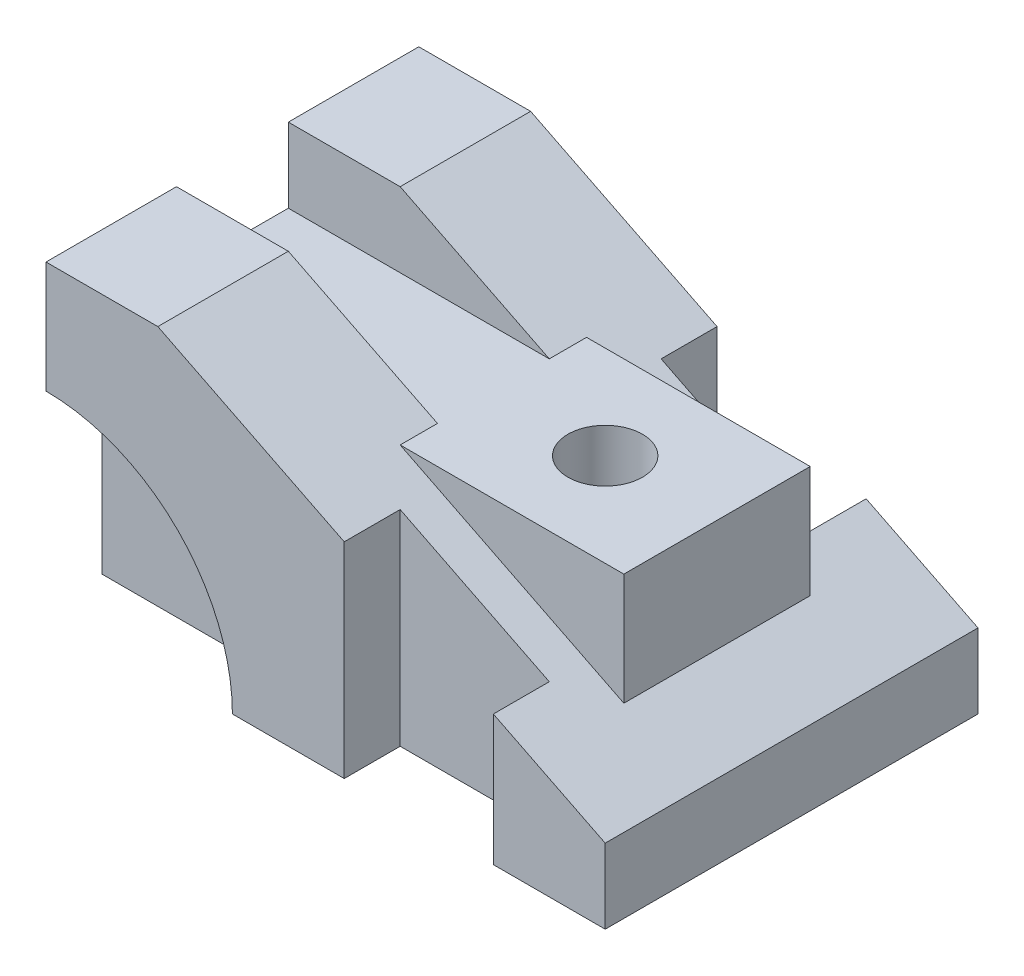
from build123d import *

# Parameters (mm, degrees)
BOSS_EXTRUDE1_DEPTH = 100
SKETCH2_R           = 50
CUT_EXTRUDE1_DEPTH  = 15
SKETCH3_R           = 50
CUT_EXTRUDE2_DEPTH  = 15
SKETCH4_W           = 40
SKETCH4_H           = 15
CUT_EXTRUDE3_DEPTH  = 75
SKETCH5_W           = 60
SKETCH5_H           = 50
BOSS_EXTRUDE2_DEPTH = 60
SKETCH7_W           = 30
SKETCH7_H           = 20
CUT_EXTRUDE4_DEPTH  = 100
SKETCH8_R           = 10
CUT_EXTRUDE5_DEPTH  = 100


with BuildPart() as part:
    # Sketch1 → Boss-Extrude1 (new body)
    with BuildSketch(Plane.XY):
        Polygon((-52.06185567, 38.608247423), (-52.06185567, -41.391752577), (97.93814433, -41.391752577), (97.93814433, -21.391752577), (-22.06185567, 38.608247423), align=None)
    extrude(amount=-BOSS_EXTRUDE1_DEPTH)

    # Sketch2 → Cut-Extrude1 (cut)
    with BuildSketch(Plane.XY):
        with Locations((-52.06185567, -41.391752577)):
            Circle(SKETCH2_R)
    extrude(amount=-CUT_EXTRUDE1_DEPTH, mode=Mode.SUBTRACT)

    # Sketch3 → Cut-Extrude2 (cut)
    with BuildSketch(Plane(origin=(0, 0, -100), x_dir=(-1, 0, 0), z_dir=(0, 0, -1))):
        with Locations((52.06185567, -41.391752577)):
            Circle(SKETCH3_R)
    extrude(amount=-CUT_EXTRUDE2_DEPTH, mode=Mode.SUBTRACT)

    # Sketch4 → Cut-Extrude3 (cut)
    with BuildSketch(Plane.XZ.offset(41.391752577)):
        with Locations((47.93814433, -7.5)):
            Rectangle(SKETCH4_W, SKETCH4_H)
        with Locations((47.93814433, -92.5)):
            Rectangle(SKETCH4_W, SKETCH4_H)
    extrude(amount=-CUT_EXTRUDE3_DEPTH, mode=Mode.SUBTRACT)

    # Sketch5 → Boss-Extrude2 (add)
    with BuildSketch(Plane.XZ.offset(41.391752577)):
        with Locations((47.93814433, -50)):
            Rectangle(SKETCH5_W, SKETCH5_H)
    extrude(amount=-BOSS_EXTRUDE2_DEPTH)

    # Sketch7 → Cut-Extrude4 (cut)
    with BuildSketch(Plane.ZY.offset(52.06185567)):
        with Locations((-50, 28.608247423)):
            Rectangle(SKETCH7_W, SKETCH7_H)
    extrude(amount=-CUT_EXTRUDE4_DEPTH, mode=Mode.SUBTRACT)

    # Sketch8 → Cut-Extrude5 (cut)
    with BuildSketch(Plane(origin=(0, 18.608247423, 0), x_dir=(1, 0, 0), z_dir=(0, 1, 0))):
        with Locations((47.93814433, 50)):
            Circle(SKETCH8_R)
    extrude(amount=-CUT_EXTRUDE5_DEPTH, mode=Mode.SUBTRACT)


solid = part.part
